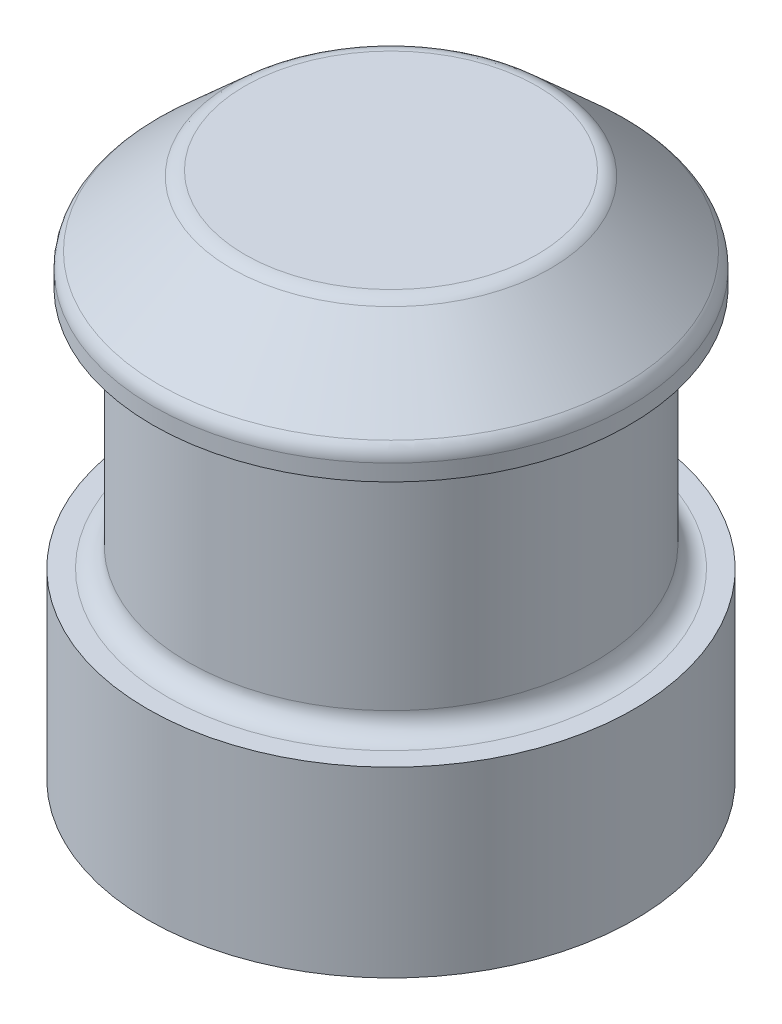
from build123d import *

# Parameters (mm, degrees)
SKETCH1_R           = 2.4
BOSS_EXTRUDE1_DEPTH = 1.8
SKETCH2_R           = 2
BOSS_EXTRUDE2_DEPTH = 2.4
SKETCH3_R           = 2.35
BOSS_EXTRUDE3_DEPTH = 1
CHAMFER1_SIZE       = 0.75
CHAMFER1_SIZE2      = 0.832959386
FILLET1_R           = 0.2
SCALE1_SCALE        = 1.15


with BuildPart() as part:
    # Sketch1 → Boss-Extrude1 (new body)
    with BuildSketch(Plane(origin=(0, 0, 0), x_dir=(1, 0, 0), z_dir=(0, 1, 0))):
        Circle(SKETCH1_R)
    extrude(amount=BOSS_EXTRUDE1_DEPTH)

    # Sketch2 → Boss-Extrude2 (add)
    with BuildSketch(Plane(origin=(0, 1.8, 0), x_dir=(1, 0, 0), z_dir=(0, 1, 0))):
        Circle(SKETCH2_R)
    extrude(amount=BOSS_EXTRUDE2_DEPTH)

    # Sketch3 → Boss-Extrude3 (add)
    with BuildSketch(Plane(origin=(0, 4.2, 0), x_dir=(1, 0, 0), z_dir=(0, 1, 0))):
        Circle(SKETCH3_R)
    extrude(amount=BOSS_EXTRUDE3_DEPTH)

    # Chamfer1
    chamfer1_edges = [part.edges().sort_by_distance(p)[0] for p in [
        (-2.35, 5.2, 0),
    ]]
    chamfer1_side = [part.faces().sort_by_distance(p)[0] for p in [
        (-2.35, 4.7, 0),
    ]]
    chamfer(chamfer1_edges, length=CHAMFER1_SIZE, length2=CHAMFER1_SIZE2, reference=chamfer1_side[0])

    # Fillet1
    fillet1_edges = [part.edges().sort_by_distance(p)[0] for p in [
        (-1.517040614, 5.2, 0),
        (-2.35, 4.45, 0),
        (-2, 1.8, 0),
    ]]
    fillet(fillet1_edges, radius=FILLET1_R)


with BuildPart() as part_1:
    # Scale1: scaled about (-4.5e-08, 2.382820286, 0)
    add(part.part.scale(SCALE1_SCALE).moved(Location((7e-09, -0.357423043, 0))))


solid = part_1.part
